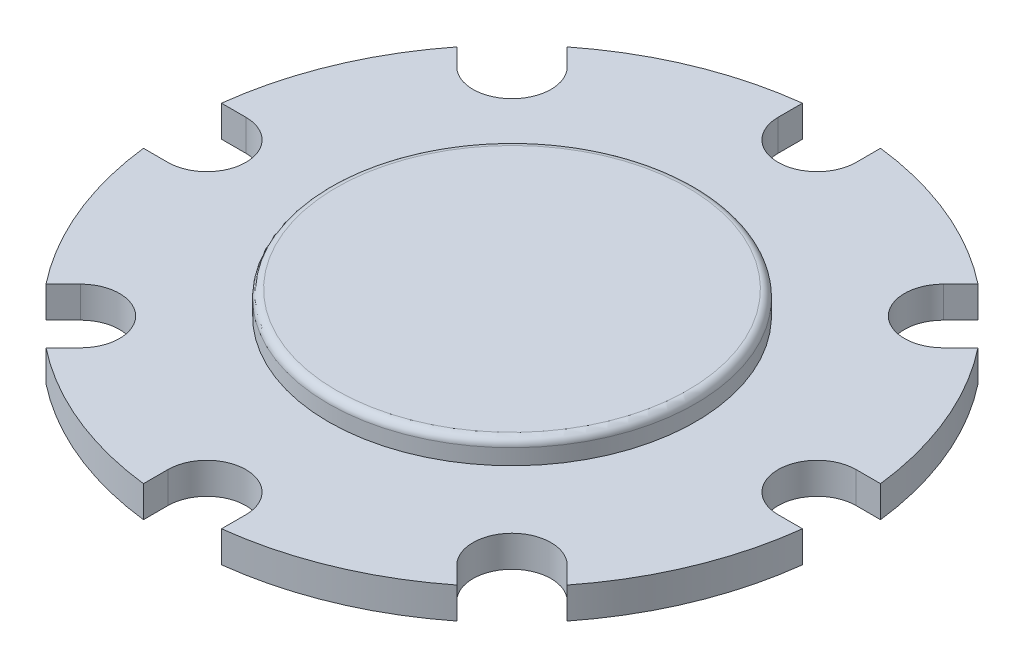
from build123d import *

# Parameters (mm, degrees)
SKETCH1_R           = 21.25
BOSS_EXTRUDE1_DEPTH = 2
SKETCH2_R           = 11.75
BOSS_EXTRUDE2_DEPTH = 1.5
FILLET1_R           = 0.5
CUT_EXTRUDE2_DEPTH  = 4.5
SKETCH5_R           = 1.654382936
CUT_EXTRUDE3_DEPTH  = 0.01
CIRPATTERN1_COUNT   = 8


with BuildPart() as part:
    # Sketch1 → Boss-Extrude1 (new body)
    with BuildSketch(Plane(origin=(0, 0, 0), x_dir=(1, 0, 0), z_dir=(0, 1, 0))):
        Circle(SKETCH1_R)
    extrude(amount=BOSS_EXTRUDE1_DEPTH)

    # Sketch2 → Boss-Extrude2 (add)
    with BuildSketch(Plane(origin=(0, 2, 0), x_dir=(1, 0, 0), z_dir=(0, 1, 0))):
        Circle(SKETCH2_R)
    extrude(amount=BOSS_EXTRUDE2_DEPTH)

    # Fillet1
    fillet1_edges = [part.edges().sort_by_distance(p)[0] for p in [
        (-11.75, 3.5, 0),
    ]]
    fillet(fillet1_edges, radius=FILLET1_R)

    # Sketch4 → Cut-Extrude2 (cut, through all)
    with BuildSketch(Plane.XZ):
        with BuildLine():
            Line((-2.5, 19.54), (-2.5, 23.75))
            Line((-2.5, 23.75), (2.5, 23.75))
            Line((2.5, 23.75), (2.5, 19.54))
            ThreePointArc((2.5, 19.54), (0, 17.04), (-2.5, 19.54))
        make_face()
    cut_extrude2 = extrude(amount=-CUT_EXTRUDE2_DEPTH, mode=Mode.SUBTRACT)

    # Sketch5 → Cut-Extrude3 (cut)
    with BuildSketch(Plane(origin=(0, 0, 0), x_dir=(-1, 0, 0), z_dir=(0, -1, 0))):
        Circle(SKETCH5_R)
    extrude(amount=-CUT_EXTRUDE3_DEPTH, mode=Mode.SUBTRACT)

    # CirPattern1: Cut-Extrude2 ×8 about axis
    cirpattern1_axis = Axis((0, 0, 0), (0, 1, 0))
    for i in range(1, CIRPATTERN1_COUNT):
        add(cut_extrude2.rotate(cirpattern1_axis, i * 360 / CIRPATTERN1_COUNT), mode=Mode.SUBTRACT)


solid = part.part
